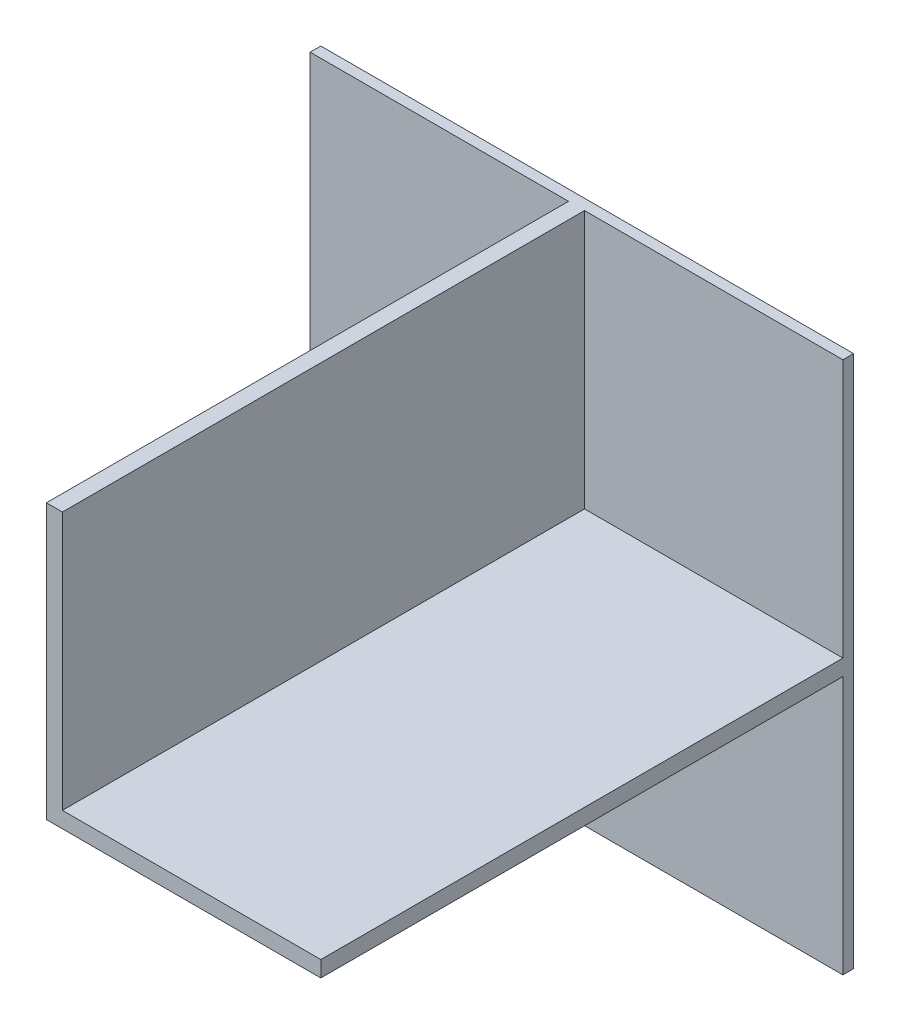
from build123d import *

# Parameters (mm, degrees)
SZKIC1_W                    = 100
SZKIC1_H                    = 100
DODANIE_WYCI_GNI_CIE1_DEPTH = 4
DODANIE_WYCI_GNI_CIE3_DEPTH = 196


with BuildPart() as part:
    # Szkic1 → Dodanie-wyciągnięcie1 (new body)
    with BuildSketch(Plane.XY):
        with Locations((-50, 50)):
            Rectangle(SZKIC1_W, SZKIC1_H)
        with Locations((50, 50)):
            Rectangle(SZKIC1_W, SZKIC1_H)
        with Locations((50, -50)):
            Rectangle(SZKIC1_W, SZKIC1_H)
        with Locations((-50, -50)):
            Rectangle(SZKIC1_W, SZKIC1_H)
    extrude(amount=DODANIE_WYCI_GNI_CIE1_DEPTH)

    # Szkic2 → Dodanie-wyciągnięcie3 (add)
    with BuildSketch(Plane.XY.offset(4)):
        Polygon((100, 3), (3, 3), (3, 100), (-3, 100), (-3, -3), (100, -3), align=None)
    extrude(amount=DODANIE_WYCI_GNI_CIE3_DEPTH)


solid = part.part
